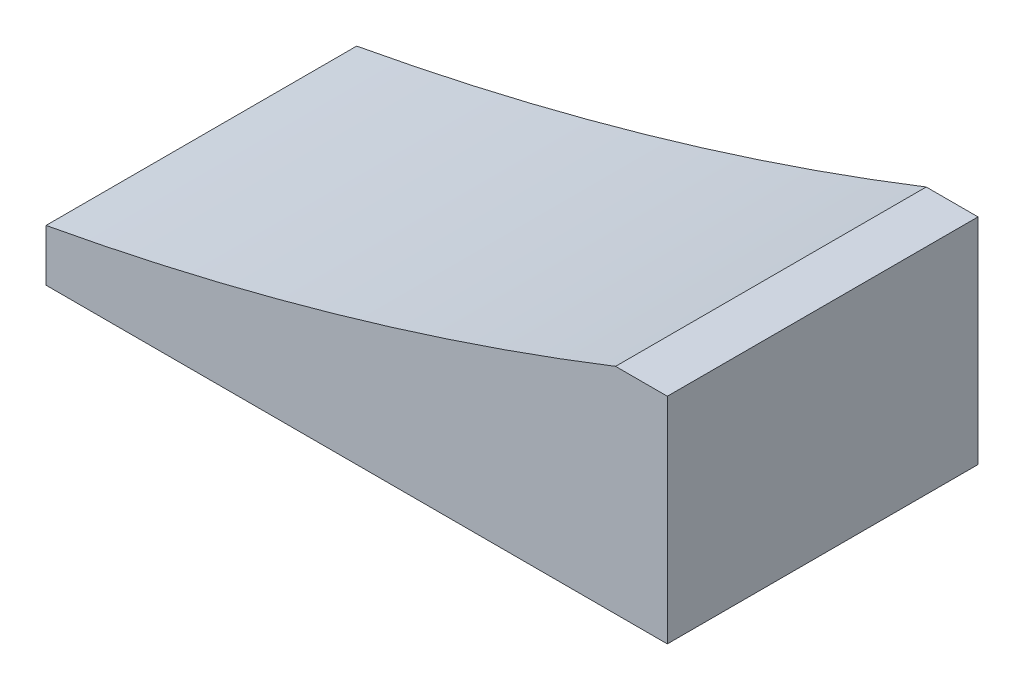
from build123d import *

# Parameters (mm, degrees)
BOSS_EXTRUDE1_DEPTH = 30


with BuildPart() as part:
    # Sketch2 → Boss-Extrude1 (new body)
    with BuildSketch(Plane.XY):
        with BuildLine():
            Line((54.543560573, -295), (54.543560573, -300))
            Line((54.543560573, -300), (114.543560573, -300))
            Line((114.543560573, -300), (114.543560573, -279.285173858))
            Line((114.543560573, -279.285173858), (109.543560573, -279.285173858))
            ThreePointArc((109.543560573, -279.285173858), (82.418958812, -288.456435581), (54.543560573, -295))
        make_face()
    extrude(amount=BOSS_EXTRUDE1_DEPTH)


solid = part.part
